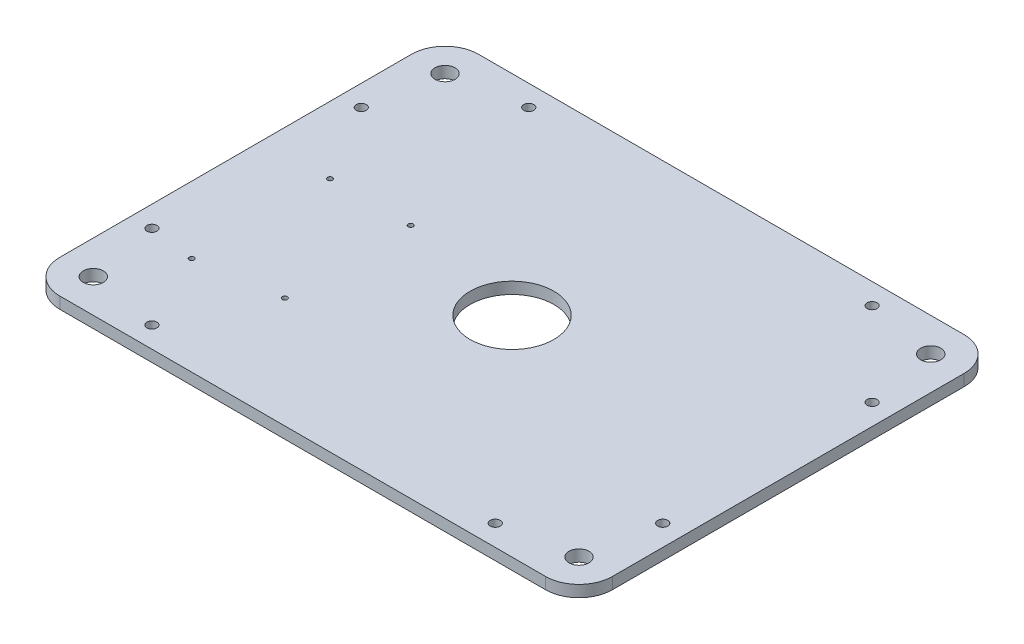
from build123d import *

# Parameters (mm, degrees)
SKETCH1_W           = 330
SKETCH1_H           = 250
BOSS_EXTRUDE1_DEPTH = 6.9
SKETCH2_R           = 6
CUT_EXTRUDE1_DEPTH  = 7.9
SKETCH3_R           = 25
CUT_EXTRUDE2_DEPTH  = 7.9
SKETCH4_R           = 3
CUT_EXTRUDE3_DEPTH  = 7.9
FILLET1_R           = 20
SKETCH5_R           = 1.5
CUT_EXTRUDE4_DEPTH  = 7.9


with BuildPart() as part:
    # Sketch1 → Boss-Extrude1 (new body)
    with BuildSketch(Plane(origin=(0, 0, 0), x_dir=(1, 0, 0), z_dir=(0, 1, 0))):
        Rectangle(SKETCH1_W, SKETCH1_H)
    extrude(amount=BOSS_EXTRUDE1_DEPTH)

    # Sketch2 → Cut-Extrude1 (cut, through all)
    with BuildSketch(Plane(origin=(0, 6.9, 0), x_dir=(1, 0, 0), z_dir=(0, 1, 0))):
        with Locations((-145, 105)):
            Circle(SKETCH2_R)
        with Locations((145, 105)):
            Circle(SKETCH2_R)
        with Locations((145, -105)):
            Circle(SKETCH2_R)
        with Locations((-145, -105)):
            Circle(SKETCH2_R)
    extrude(amount=-CUT_EXTRUDE1_DEPTH, mode=Mode.SUBTRACT)

    # Sketch3 → Cut-Extrude2 (cut, through all)
    with BuildSketch(Plane(origin=(0, 6.9, 0), x_dir=(1, 0, 0), z_dir=(0, 1, 0))):
        Circle(SKETCH3_R)
    extrude(amount=-CUT_EXTRUDE2_DEPTH, mode=Mode.SUBTRACT)

    # Sketch4 → Cut-Extrude3 (cut, through all)
    with BuildSketch(Plane(origin=(0, 6.9, 0), x_dir=(1, 0, 0), z_dir=(0, 1, 0))):
        with Locations((-152.5, -62.5)):
            Circle(SKETCH4_R)
        with Locations((-102.5, -112.5)):
            Circle(SKETCH4_R)
        with Locations((-102.5, 112.5)):
            Circle(SKETCH4_R)
        with Locations((-152.5, 62.5)):
            Circle(SKETCH4_R)
        with Locations((152.5, 62.5)):
            Circle(SKETCH4_R)
        with Locations((102.5, 112.5)):
            Circle(SKETCH4_R)
        with Locations((102.5, -112.5)):
            Circle(SKETCH4_R)
        with Locations((152.5, -62.5)):
            Circle(SKETCH4_R)
    extrude(amount=-CUT_EXTRUDE3_DEPTH, mode=Mode.SUBTRACT)

    # Fillet1
    fillet1_edges = [part.edges().sort_by_distance(p)[0] for p in [
        (-165, 3.45, -125),
        (165, 3.45, -125),
        (165, 3.45, 125),
        (-165, 3.45, 125),
    ]]
    fillet(fillet1_edges, radius=FILLET1_R)

    # Sketch5 → Cut-Extrude4 (cut, through all)
    with BuildSketch(Plane(origin=(0, 6.9, 0), x_dir=(1, 0, 0), z_dir=(0, 1, 0))):
        with Locations((-125, 16.275)):
            Circle(SKETCH5_R)
        with Locations((-76.74, 16.275)):
            Circle(SKETCH5_R)
        with Locations((-125, -66.275)):
            Circle(SKETCH5_R)
        with Locations((-76.74, -58.909)):
            Circle(SKETCH5_R)
    extrude(amount=-CUT_EXTRUDE4_DEPTH, mode=Mode.SUBTRACT)


solid = part.part
